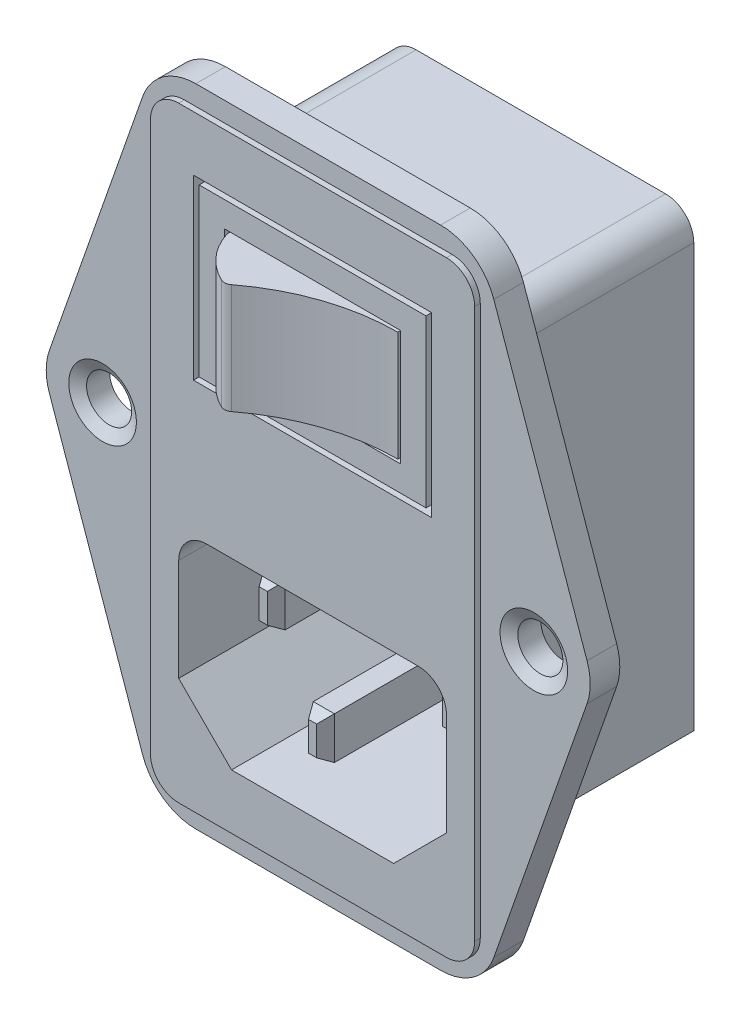
from build123d import *
from OCP.BRepFilletAPI import BRepFilletAPI_MakeChamfer

# Parameters (mm, degrees)
BOSS_EXTRUDE1_DEPTH = 3.175
CUT_EXTRUDE1_DEPTH  = 0.508
SKETCH3_W           = 21.463
SKETCH3_H           = 16.002
SKETCH3_W_2         = 20.447
SKETCH3_H_2         = 14.986
SKETCH3_W_3         = 15.875
SKETCH3_H_3         = 10.414
CUT_EXTRUDE2_DEPTH  = 2.54
BOSS_EXTRUDE3_DEPTH = 9.906
BOSS_EXTRUDE4_DEPTH = 17.399
SKETCH7_W           = 1.905
SKETCH7_H           = 3.81
CUT_EXTRUDE3_DEPTH  = 16.51
SKETCH8_W           = 1.905
SKETCH8_H           = 3.81
CUT_EXTRUDE4_DEPTH  = 3.81
CHAMFER1_SIZE       = 1.016
CHAMFER1_SIZE2      = 0.586587873
FILLET1_R           = 2.54
SKETCH9_R           = 2.032
CUT_EXTRUDE5_DEPTH  = 44.002957642
CHAMFER2_SIZE       = 1.016
CHAMFER2_SIZE2      = 0.586587873


with BuildPart() as part:
    # Sketch1 → Boss-Extrude1 (new body)
    with BuildSketch(Plane.XY):
        with BuildLine():
            Line((-11.03046671, 29.083), (11.03046671, 29.083))
            ThreePointArc((11.03046671, 29.083), (13.97, 28.146132153), (15.825299343, 25.681088204))
            Line((15.825299343, 25.681088204), (24.225832633, 1.678088204))
            ThreePointArc((24.225832633, 1.678088204), (24.511, 0), (24.225832633, -1.678088204))
            Line((24.225832633, -1.678088204), (15.825299343, -25.681088204))
            ThreePointArc((15.825299343, -25.681088204), (13.97, -28.146132153), (11.03046671, -29.083))
            Line((11.03046671, -29.083), (-11.03046671, -29.083))
            ThreePointArc((-11.03046671, -29.083), (-13.97, -28.146132153), (-15.825299343, -25.681088204))
            Line((-15.825299343, -25.681088204), (-24.225832633, -1.678088204))
            ThreePointArc((-24.225832633, -1.678088204), (-24.511, 0), (-24.225832633, 1.678088204))
            Line((-24.225832633, 1.678088204), (-15.825299343, 25.681088204))
            ThreePointArc((-15.825299343, 25.681088204), (-13.97, 28.146132153), (-11.03046671, 29.083))
        make_face()
    extrude(amount=BOSS_EXTRUDE1_DEPTH)

    # Sketch2 → Cut-Extrude1 (cut)
    with BuildSketch(Plane.XY.offset(3.175)):
        with BuildLine():
            Line((-11.03046671, -29.083), (11.03046671, -29.083))
            ThreePointArc((11.03046671, -29.083), (13.97, -28.146132153), (15.825299343, -25.681088204))
            Line((15.825299343, -25.681088204), (24.225832633, -1.678088204))
            ThreePointArc((24.225832633, -1.678088204), (24.511, 0), (24.225832633, 1.678088204))
            Line((24.225832633, 1.678088204), (15.825299343, 25.681088204))
            ThreePointArc((15.825299343, 25.681088204), (13.97, 28.146132153), (11.03046671, 29.083))
            Line((11.03046671, 29.083), (-11.03046671, 29.083))
            ThreePointArc((-11.03046671, 29.083), (-13.97, 28.146132153), (-15.825299343, 25.681088204))
            Line((-15.825299343, 25.681088204), (-24.225832633, 1.678088204))
            ThreePointArc((-24.225832633, 1.678088204), (-24.511, 0), (-24.225832633, -1.678088204))
            Line((-24.225832633, -1.678088204), (-15.825299343, -25.681088204))
            ThreePointArc((-15.825299343, -25.681088204), (-13.97, -28.146132153), (-11.03046671, -29.083))
        make_face()
        with BuildLine():
            Line((-12.065, 27.305), (12.065, 27.305))
            ThreePointArc((12.065, 27.305), (13.861051224, 26.561051224), (14.605, 24.765))
            Line((14.605, 24.765), (14.605, -24.765))
            ThreePointArc((14.605, -24.765), (13.861051224, -26.561051224), (12.065, -27.305))
            Line((12.065, -27.305), (-12.065, -27.305))
            ThreePointArc((-12.065, -27.305), (-13.861051224, -26.561051224), (-14.605, -24.765))
            Line((-14.605, -24.765), (-14.605, 24.765))
            ThreePointArc((-14.605, 24.765), (-13.861051224, 26.561051224), (-12.065, 27.305))
        make_face(mode=Mode.SUBTRACT)
    extrude(amount=-CUT_EXTRUDE1_DEPTH, mode=Mode.SUBTRACT)

    # Sketch3 → Cut-Extrude2 (cut)
    with BuildSketch(Plane.XY.offset(3.175)):
        with Locations((0, 14.351)):
            Rectangle(SKETCH3_W, SKETCH3_H)
        with Locations((0, 14.351)):
            Rectangle(SKETCH3_W_2, SKETCH3_H_2, mode=Mode.SUBTRACT)
        with Locations((0, 14.351)):
            Rectangle(SKETCH3_W_3, SKETCH3_H_3)
    extrude(amount=-CUT_EXTRUDE2_DEPTH, mode=Mode.SUBTRACT)

    # Sketch5 → Boss-Extrude3 (add)
    with BuildSketch(Plane.XZ.offset(-19.304)):
        with BuildLine():
            Line((-7.6835, 0.635), (-7.6835, 3.175))
            ThreePointArc((-7.6835, 3.175), (-6.408209158, 5.469554889), (-4.313795397, 7.052204524))
            ThreePointArc((-4.313795397, 7.052204524), (-3.908770324, 7.120088215), (-3.527334844, 6.967902539))
            ThreePointArc((-3.527334844, 6.967902539), (1.765964035, 4.148909918), (7.6835, 3.175))
            Line((7.6835, 3.175), (7.6835, 0.635))
            Line((7.6835, 0.635), (-7.6835, 0.635))
        make_face()
    extrude(amount=BOSS_EXTRUDE3_DEPTH)

    # Sketch6 → Boss-Extrude4 (add)
    with BuildSketch(Plane(origin=(0, 0, 0), x_dir=(-1, 0, 0), z_dir=(0, 0, -1))):
        with BuildLine():
            Line((-13.7795, -19.05), (-7.4295, -25.4))
            Line((-7.4295, -25.4), (7.4295, -25.4))
            Line((7.4295, -25.4), (13.7795, -19.05))
            Line((13.7795, -19.05), (13.7795, 19.05))
            ThreePointArc((13.7795, 19.05), (13.035551224, 20.846051224), (11.2395, 21.59))
            Line((11.2395, 21.59), (-11.2395, 21.59))
            ThreePointArc((-11.2395, 21.59), (-13.035551224, 20.846051224), (-13.7795, 19.05))
            Line((-13.7795, 19.05), (-13.7795, -19.05))
        make_face()
    extrude(amount=BOSS_EXTRUDE4_DEPTH)

    # Sketch7 → Cut-Extrude3 (cut)
    with BuildSketch(Plane.XY.offset(3.175)):
        Polygon((-7.3025, -22.352), (7.3025, -22.352), (12.065, -17.5895), (12.065, -5.842), (-12.065, -5.842), (-12.065, -17.5895), align=None)
        with Locations((-8.255, -11.938)):
            Rectangle(SKETCH7_W, SKETCH7_H, mode=Mode.SUBTRACT)
        with Locations((0, -16.256)):
            Rectangle(SKETCH7_W, SKETCH7_H, mode=Mode.SUBTRACT)
        with Locations((8.255, -11.938)):
            Rectangle(SKETCH7_W, SKETCH7_H, mode=Mode.SUBTRACT)
    extrude(amount=-CUT_EXTRUDE3_DEPTH, mode=Mode.SUBTRACT)

    # Sketch8 → Cut-Extrude4 (cut)
    with BuildSketch(Plane.XY.offset(3.175)):
        with Locations((8.255, -11.938)):
            Rectangle(SKETCH8_W, SKETCH8_H)
        with Locations((-8.255, -11.938)):
            Rectangle(SKETCH8_W, SKETCH8_H)
    extrude(amount=-CUT_EXTRUDE4_DEPTH, mode=Mode.SUBTRACT)

    # Chamfer1: one chamfer whose edges measure the first distance from different faces: ONE call of the kernel's chamfer builder (chamfer() names one face for all edges)
    chamfer1_edges_1 = [part.edges().sort_by_distance(p)[0] for p in [
        (-0.9525, -16.256, 3.175),
    ]]
    chamfer1_side_1 = [part.faces().sort_by_distance(p)[0] for p in [
        (-0.9525, -16.256, -5.08),
    ]]
    chamfer1_edges_2 = [part.edges().sort_by_distance(p)[0] for p in [
        (0, -14.351, 3.175),
    ]]
    chamfer1_side_2 = [part.faces().sort_by_distance(p)[0] for p in [
        (0, -14.351, -5.08),
    ]]
    chamfer1_edges_3 = [part.edges().sort_by_distance(p)[0] for p in [
        (0.9525, -16.256, 3.175),
    ]]
    chamfer1_side_3 = [part.faces().sort_by_distance(p)[0] for p in [
        (0.9525, -16.256, -5.08),
    ]]
    chamfer1_edges_4 = [part.edges().sort_by_distance(p)[0] for p in [
        (0, -18.161, 3.175),
    ]]
    chamfer1_side_4 = [part.faces().sort_by_distance(p)[0] for p in [
        (0, -18.161, -5.08),
    ]]
    chamfer1_edges_5 = [part.edges().sort_by_distance(p)[0] for p in [
        (8.255, -10.033, -0.635),
    ]]
    chamfer1_side_5 = [part.faces().sort_by_distance(p)[0] for p in [
        (8.255, -10.033, -6.985),
    ]]
    chamfer1_edges_6 = [part.edges().sort_by_distance(p)[0] for p in [
        (9.2075, -11.938, -0.635),
    ]]
    chamfer1_side_6 = [part.faces().sort_by_distance(p)[0] for p in [
        (9.2075, -11.938, -6.985),
    ]]
    chamfer1_edges_7 = [part.edges().sort_by_distance(p)[0] for p in [
        (8.255, -13.843, -0.635),
    ]]
    chamfer1_side_7 = [part.faces().sort_by_distance(p)[0] for p in [
        (8.255, -13.843, -6.985),
    ]]
    chamfer1_edges_8 = [part.edges().sort_by_distance(p)[0] for p in [
        (7.3025, -11.938, -0.635),
    ]]
    chamfer1_side_8 = [part.faces().sort_by_distance(p)[0] for p in [
        (7.3025, -11.938, -6.985),
    ]]
    chamfer1_edges_9 = [part.edges().sort_by_distance(p)[0] for p in [
        (-8.255, -10.033, -0.635),
    ]]
    chamfer1_side_9 = [part.faces().sort_by_distance(p)[0] for p in [
        (-8.255, -10.033, -6.985),
    ]]
    chamfer1_edges_10 = [part.edges().sort_by_distance(p)[0] for p in [
        (-7.3025, -11.938, -0.635),
    ]]
    chamfer1_side_10 = [part.faces().sort_by_distance(p)[0] for p in [
        (-7.3025, -11.938, -6.985),
    ]]
    chamfer1_edges_11 = [part.edges().sort_by_distance(p)[0] for p in [
        (-8.255, -13.843, -0.635),
    ]]
    chamfer1_side_11 = [part.faces().sort_by_distance(p)[0] for p in [
        (-8.255, -13.843, -6.985),
    ]]
    chamfer1_edges_12 = [part.edges().sort_by_distance(p)[0] for p in [
        (-9.2075, -11.938, -0.635),
    ]]
    chamfer1_side_12 = [part.faces().sort_by_distance(p)[0] for p in [
        (-9.2075, -11.938, -6.985),
    ]]
    chamfer1 = BRepFilletAPI_MakeChamfer(part.part.solid().wrapped)
    for e in chamfer1_edges_1:
        chamfer1.Add(CHAMFER1_SIZE, CHAMFER1_SIZE2, e.wrapped, chamfer1_side_1[0].wrapped)  # the first distance lies on this face
    for e in chamfer1_edges_2:
        chamfer1.Add(CHAMFER1_SIZE, CHAMFER1_SIZE2, e.wrapped, chamfer1_side_2[0].wrapped)  # the first distance lies on this face
    for e in chamfer1_edges_3:
        chamfer1.Add(CHAMFER1_SIZE, CHAMFER1_SIZE2, e.wrapped, chamfer1_side_3[0].wrapped)  # the first distance lies on this face
    for e in chamfer1_edges_4:
        chamfer1.Add(CHAMFER1_SIZE, CHAMFER1_SIZE2, e.wrapped, chamfer1_side_4[0].wrapped)  # the first distance lies on this face
    for e in chamfer1_edges_5:
        chamfer1.Add(CHAMFER1_SIZE, CHAMFER1_SIZE2, e.wrapped, chamfer1_side_5[0].wrapped)  # the first distance lies on this face
    for e in chamfer1_edges_6:
        chamfer1.Add(CHAMFER1_SIZE, CHAMFER1_SIZE2, e.wrapped, chamfer1_side_6[0].wrapped)  # the first distance lies on this face
    for e in chamfer1_edges_7:
        chamfer1.Add(CHAMFER1_SIZE, CHAMFER1_SIZE2, e.wrapped, chamfer1_side_7[0].wrapped)  # the first distance lies on this face
    for e in chamfer1_edges_8:
        chamfer1.Add(CHAMFER1_SIZE, CHAMFER1_SIZE2, e.wrapped, chamfer1_side_8[0].wrapped)  # the first distance lies on this face
    for e in chamfer1_edges_9:
        chamfer1.Add(CHAMFER1_SIZE, CHAMFER1_SIZE2, e.wrapped, chamfer1_side_9[0].wrapped)  # the first distance lies on this face
    for e in chamfer1_edges_10:
        chamfer1.Add(CHAMFER1_SIZE, CHAMFER1_SIZE2, e.wrapped, chamfer1_side_10[0].wrapped)  # the first distance lies on this face
    for e in chamfer1_edges_11:
        chamfer1.Add(CHAMFER1_SIZE, CHAMFER1_SIZE2, e.wrapped, chamfer1_side_11[0].wrapped)  # the first distance lies on this face
    for e in chamfer1_edges_12:
        chamfer1.Add(CHAMFER1_SIZE, CHAMFER1_SIZE2, e.wrapped, chamfer1_side_12[0].wrapped)  # the first distance lies on this face
    add(Compound.cast(chamfer1.Shape()), mode=Mode.REPLACE)

    # Fillet1
    fillet1_edges = [part.edges().sort_by_distance(p)[0] for p in [
        (-12.065, -5.842, -5.08),
        (12.065, -5.842, -5.08),
    ]]
    fillet(fillet1_edges, radius=FILLET1_R)

    # Sketch9 → Cut-Extrude5 (cut, through all)
    with BuildSketch(Plane.XY.offset(2.667)):
        with Locations((-19.431, 0)):
            Circle(SKETCH9_R)
        with Locations((19.431, 0)):
            Circle(SKETCH9_R)
    extrude(amount=-CUT_EXTRUDE5_DEPTH, mode=Mode.SUBTRACT)

    # Chamfer2
    chamfer2_edges = [part.edges().sort_by_distance(p)[0] for p in [
        (-21.463, 0, 2.667),
        (17.399, 0, 2.667),
    ]]
    chamfer2_side = [part.faces().sort_by_distance(p)[0] for p in [
        (-23.750313465, 0, 2.667),
    ]]
    chamfer(chamfer2_edges, length=CHAMFER2_SIZE, length2=CHAMFER2_SIZE2, reference=chamfer2_side[0])


solid = part.part
